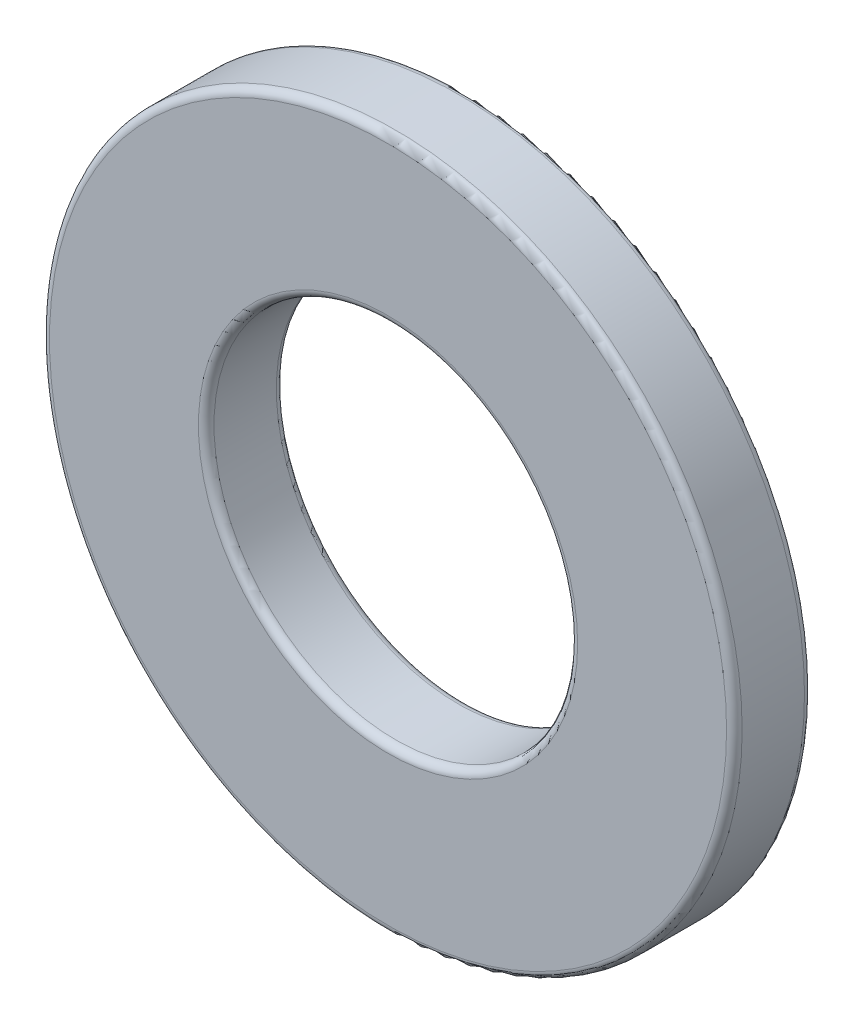
from build123d import *

# Parameters (mm, degrees)
SKETCH3_R                = 8
SKETCH3_R_2              = 4.2
BOSS_EXTRUDE1_DEPTH      = 0.9
BOSS_EXTRUDE1_DEPTH_BACK = 0.9
FILLET1_R                = 0.18


with BuildPart() as part:
    # Sketch3 → Boss-Extrude1 (new body, two sides)
    with BuildSketch(Plane.XY) as boss_extrude1_sk:
        Circle(SKETCH3_R)
        Circle(SKETCH3_R_2, mode=Mode.SUBTRACT)
    extrude(amount=BOSS_EXTRUDE1_DEPTH)
    extrude(boss_extrude1_sk.sketch, amount=-BOSS_EXTRUDE1_DEPTH_BACK)

    # Fillet1
    fillet1_edges = [part.edges().sort_by_distance(p)[0] for p in [
        (-8, 0, -0.9),
        (-4.2, 0, -0.9),
        (-8, 0, 0.9),
        (-4.2, 0, 0.9),
    ]]
    fillet(fillet1_edges, radius=FILLET1_R)


solid = part.part
